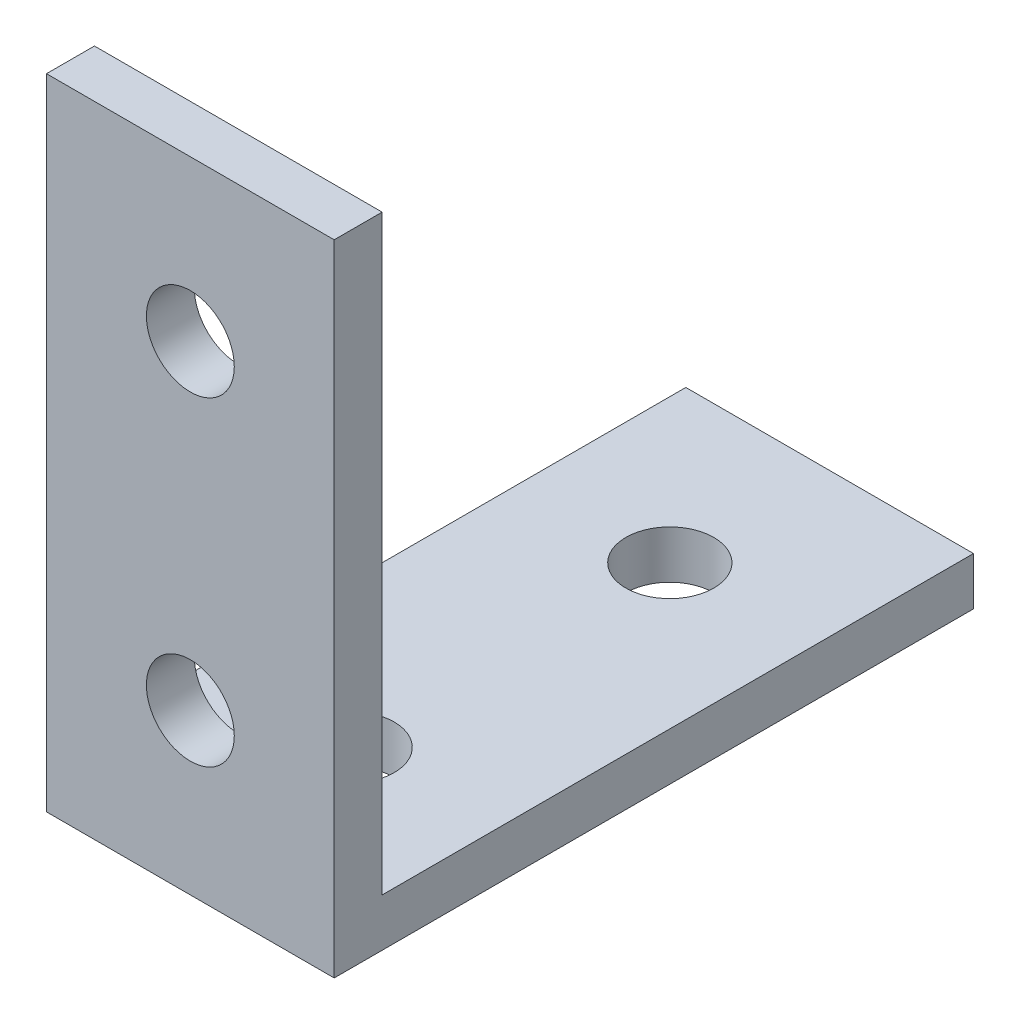
from build123d import *

# Parameters (mm, degrees)
EXTRUDE_1_DEPTH          = 18
SKETCH_3_R               = 2.75
CUT_EXTRUDE_1_DEPTH      = 1
CUT_EXTRUDE_1_DEPTH_BACK = 41
CUT_EXTRUDE_2_REACH      = 42
SKETCH_4_R               = 2.75


with BuildPart() as part:
    # 草图1 → 凸台-拉伸1 (new body)
    with BuildSketch(Plane(origin=(0, 0, 0), x_dir=(0, 0, -1), z_dir=(1, 0, 0))):
        Polygon((0, 0), (0, -40), (40, -40), (40, -37), (3, -37), (3, 0), align=None)
    extrude(amount=EXTRUDE_1_DEPTH)

    # 草图3 → 切除-拉伸1 (cut, two sides)
    with BuildSketch(Plane.XZ.offset(40)) as cut_extrude_1_sk:
        with Locations((9, -10)):
            Circle(SKETCH_3_R)
        with Locations((9, -30)):
            Circle(SKETCH_3_R)
    extrude(amount=CUT_EXTRUDE_1_DEPTH, mode=Mode.SUBTRACT)
    extrude(cut_extrude_1_sk.sketch, amount=-CUT_EXTRUDE_1_DEPTH_BACK, mode=Mode.SUBTRACT)

    # 草图4 → 切除-拉伸2 (cut, up to next)
    with BuildSketch(Plane(origin=(0, 0, 0), x_dir=(-1, 0, 0), z_dir=(0, 0, 1)), mode=Mode.PRIVATE) as cut_extrude_2_sk1:
        with Locations((-9, 30)):
            Circle(SKETCH_4_R)
    cut_extrude_2_tool1 = extrude(cut_extrude_2_sk1.sketch, amount=-CUT_EXTRUDE_2_REACH, mode=Mode.PRIVATE) & part.part
    add(cut_extrude_2_tool1.solids().sort_by_distance((9, -30, 0))[0], mode=Mode.SUBTRACT)
    # 草图4 → 切除-拉伸2 (cut, up to next)
    with BuildSketch(Plane(origin=(0, 0, 0), x_dir=(-1, 0, 0), z_dir=(0, 0, 1)), mode=Mode.PRIVATE) as cut_extrude_2_sk2:
        with Locations((-9, 10)):
            Circle(SKETCH_4_R)
    cut_extrude_2_tool2 = extrude(cut_extrude_2_sk2.sketch, amount=-CUT_EXTRUDE_2_REACH, mode=Mode.PRIVATE) & part.part
    add(cut_extrude_2_tool2.solids().sort_by_distance((9, -10, 0))[0], mode=Mode.SUBTRACT)


solid = part.part
